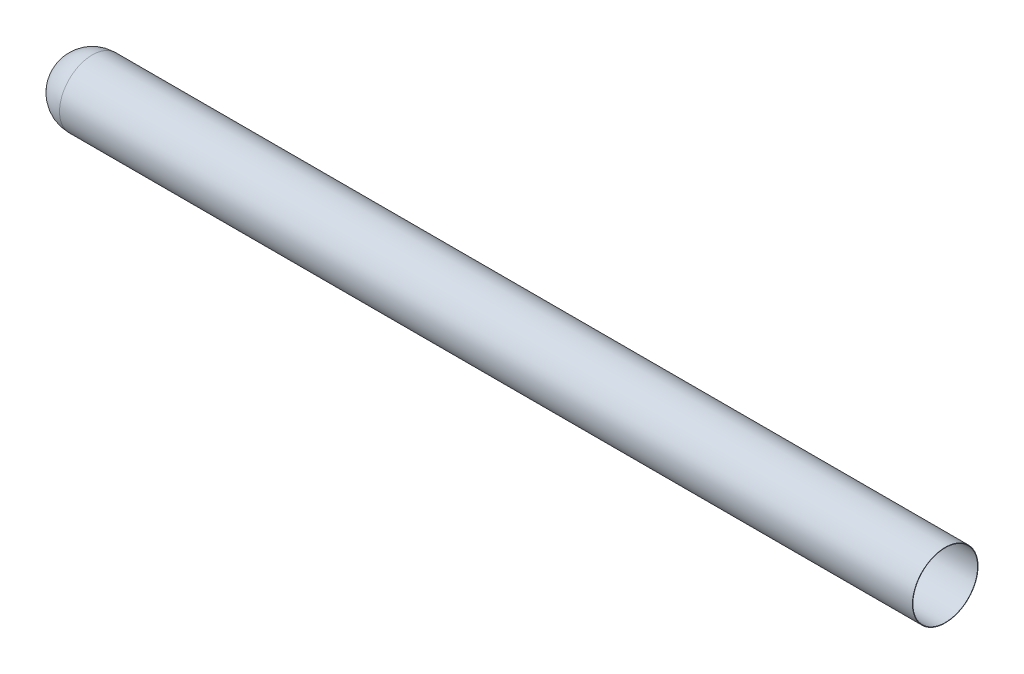
from build123d import *


with BuildPart() as part:
    # rootSketch → Revolve1 (revolve)
    with BuildSketch(Plane(origin=(0, 0, 0), x_dir=(1, 0, 0), z_dir=(0, 1, 0))):
        with BuildLine():
            Line((250, -250), (6750, -250))
            Line((6750, -250), (6750, -246.825))
            Line((6750, -246.825), (250, -246.825))
            ThreePointArc((250, -246.825), (75.468368734, -174.531631266), (3.175, 0))
            Line((3.175, 0), (0, 0))
            ThreePointArc((0, 0), (73.223304703, -176.776695297), (250, -250))
        make_face()
    revolve(axis=Axis((0, 0, 0), (1, 0, 0)))


solid = part.part
